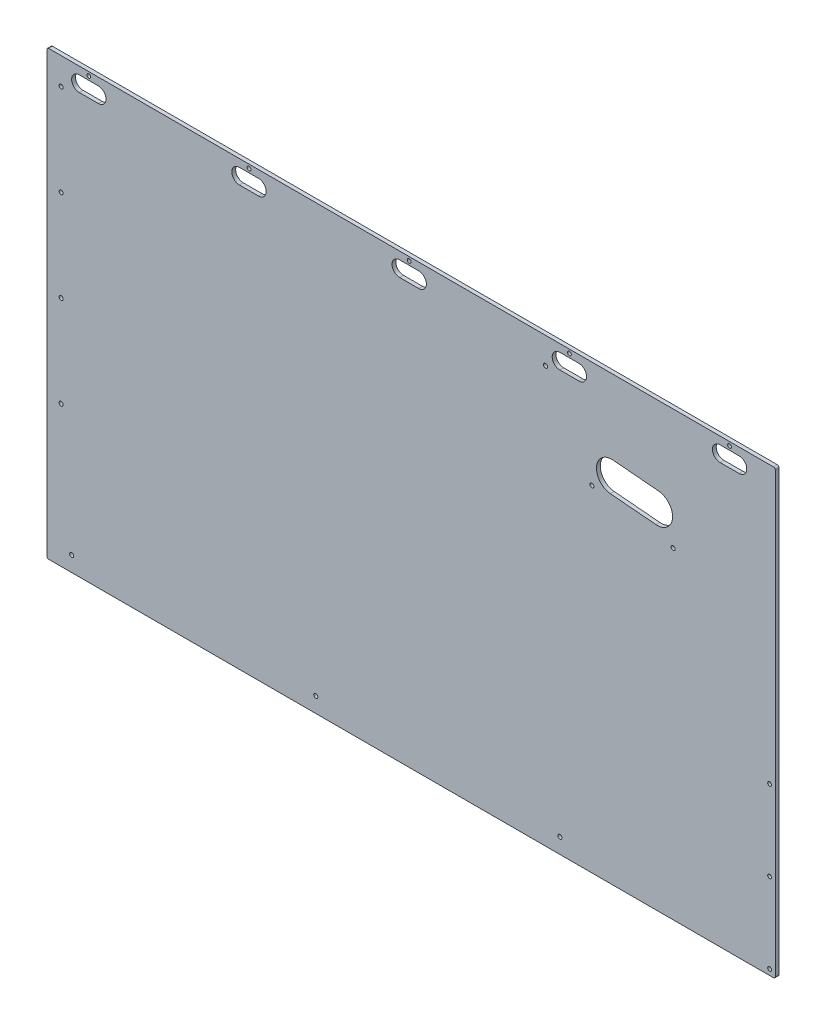
from build123d import *

# Parameters (mm, degrees)
SKETCH1_W                   = 1212.85
SKETCH1_H                   = 736.6
BOSS_EXTRUDE1_DEPTH         = 6.35
H_0_266_DIAMETER_HOLE1_D    = 6.7564
H_0_266_DIAMETER_HOLE2_D    = 6.7564
H_0_266_DIAMETER_HOLE3_D    = 6.7564
SKETCH12_R                  = 3.175
CUT_EXTRUDE4_DEPTH          = 7.35
LPATTERN1_COUNT             = 5
LPATTERN1_PITCH             = 266.7
FILLET2_R                   = 3.175
CUT_EXTRUDE5_DEPTH          = 7.35
F_1_4_0_25_DIAMETER_HOLE1_D = 6.35


with BuildPart() as part:
    # Sketch1 → Boss-Extrude1 (new body)
    with BuildSketch(Plane.XY):
        Rectangle(SKETCH1_W, SKETCH1_H)
    extrude(amount=BOSS_EXTRUDE1_DEPTH)

    # H (0.266) Diameter Hole1 (through all)
    with Locations(Plane.XY.offset(6.35)):
        with Locations((-565.15, -342.9), (-158.75, -342.9), (247.65, -342.9)):
            Hole(H_0_266_DIAMETER_HOLE1_D / 2)

    # H (0.266) Diameter Hole2 (through all)
    with Locations(Plane.XY.offset(6.35)):
        with Locations((-582.6125, 323.596), (-582.6125, 171.196), (-582.6125, 18.796), (-582.6125, -133.604)):
            Hole(H_0_266_DIAMETER_HOLE2_D / 2)

    # H (0.266) Diameter Hole3 (through all)
    with Locations(Plane.XY.offset(6.35)):
        with Locations((223.770762516, 324.305909426), (436.157706379, 167.711380386), (301.059782944, 190.437399177)):
            Hole(H_0_266_DIAMETER_HOLE3_D / 2)

    # Sketch12 → Cut-Extrude4 (cut, through all)
    with BuildSketch(Plane.XY.offset(6.35)):
        with Locations((-536.575, 361.95)):
            Circle(SKETCH12_R)
        with BuildLine():
            Line((-552.45, 355.6), (-520.7, 355.6))
            ThreePointArc((-520.7, 355.6), (-508, 342.9), (-520.7, 330.2))
            Line((-520.7, 330.2), (-552.45, 330.2))
            ThreePointArc((-552.45, 330.2), (-565.15, 342.9), (-552.45, 355.6))
        make_face()
    cut_extrude4 = extrude(amount=-CUT_EXTRUDE4_DEPTH, mode=Mode.SUBTRACT)

    # LPattern1: Cut-Extrude4 ×5
    with Locations(*[(i * LPATTERN1_PITCH, 0, 0) for i in range(1, LPATTERN1_COUNT)]):
        add(cut_extrude4, mode=Mode.SUBTRACT)

    # Fillet2
    fillet2_edges = [part.edges().sort_by_distance(p)[0] for p in [
        (606.425, -368.3, 3.175),
        (-606.425, -368.3, 3.175),
        (-606.425, 368.3, 3.175),
        (606.425, 368.3, 3.175),
    ]]
    fillet(fillet2_edges, radius=FILLET2_R)

    # Sketch14 → Cut-Extrude5 (cut, through all)
    with BuildSketch(Plane.XY.offset(6.35)):
        with BuildLine():
            Line((336.240912114, 244.52397913), (412.150948109, 237.882711533))
            ThreePointArc((412.150948109, 237.882711533), (435.240537575, 210.365610336), (407.723436378, 187.27602087))
            Line((407.723436378, 187.27602087), (331.813400383, 193.917288467))
            ThreePointArc((331.813400383, 193.917288467), (308.723810917, 221.434389664), (336.240912114, 244.52397913))
        make_face()
    extrude(amount=-CUT_EXTRUDE5_DEPTH, mode=Mode.SUBTRACT)

    # 1/4 (0.25) Diameter Hole1 (through all)
    with Locations(Plane.XY.offset(6.35)):
        with Locations((596.9, -358.775), (596.9, -225.425), (596.9, -92.075)):
            Hole(F_1_4_0_25_DIAMETER_HOLE1_D / 2)


solid = part.part
